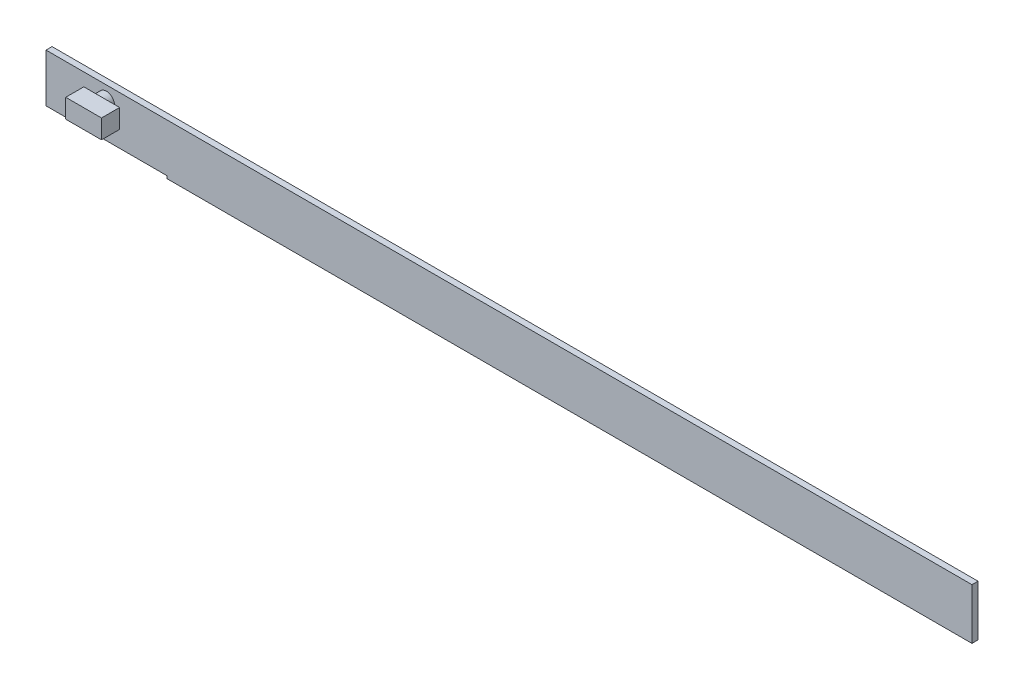
from build123d import *

# Parameters (mm, degrees)
SKETCH2_W           = 254
SKETCH2_H           = 12.7
BOSS_EXTRUDE1_DEPTH = 101.6
SKETCH3_R           = 17.140791438
BOSS_EXTRUDE2_DEPTH = 19.05
SKETCH4_W           = 75.235944222
SKETCH4_H           = 39.955088207
BOSS_EXTRUDE3_DEPTH = 38.1
SCALE2_SCALE        = 0.00375
ROTATE_ANGLE        = 90
SKETCH6_W           = 6.35
SKETCH6_H           = 0.047625
BOSS_EXTRUDE6_DEPTH = 0.40132


with BuildPart() as part:
    # Sketch2 → Boss-Extrude1 (new body)
    with BuildSketch(Plane.XY):
        with Locations((79.130769231, 14.898076923)):
            Rectangle(SKETCH2_W, SKETCH2_H)
    extrude(amount=BOSS_EXTRUDE1_DEPTH)

    # Sketch3 → Boss-Extrude2 (add)
    with BuildSketch(Plane(origin=(0, 21.248076923, 0), x_dir=(1, 0, 0), z_dir=(0, 1, 0))):
        with Locations((79.130769231, -28.483063876)):
            Circle(SKETCH3_R)
    extrude(amount=BOSS_EXTRUDE2_DEPTH)

    # Sketch4 → Boss-Extrude3 (add)
    with BuildSketch(Plane(origin=(0, 40.298076923, 0), x_dir=(1, 0, 0), z_dir=(0, 1, 0))):
        with Locations((88.38546847, -28.088530296)):
            Rectangle(SKETCH4_W, SKETCH4_H)
    extrude(amount=BOSS_EXTRUDE3_DEPTH)


with BuildPart() as part_1:
    # Scale2: scaled about (81.435728249, 26.575729378, 44.290186425)
    add(part.part.scale(SCALE2_SCALE).moved(Location((81.130344268, 26.476070393, 44.124098226))))


with BuildPart() as part_2:
    # rotate: moved
    add(part_1.part.rotate(Axis((0, 33.666927966, 26.550068274), (1, 0, 0)), ROTATE_ANGLE))


with BuildPart() as part_3:
    # Move Body 4 x: moved
    add(part_2.part.moved(Location((-101.6, 0, 0))))


with BuildPart() as part_4:
    # Move Body 2 y: moved
    add(part_3.part.moved(Location((0, -55.88, 0))))


with BuildPart() as part_5:
    # Move Body 2.1z: moved
    add(part_4.part.moved(Location((0, 0, -30.48))))

    # Sketch6 → Boss-Extrude6 (add)
    with BuildSketch(Plane(origin=(0, -39.787101985, 0), x_dir=(1, 0, 0), z_dir=(0, 1, 0))):
        with Locations((-16.521665348, 11.064921511)):
            Rectangle(SKETCH6_W, SKETCH6_H)
    extrude(amount=-BOSS_EXTRUDE6_DEPTH)


solid = part_5.part
